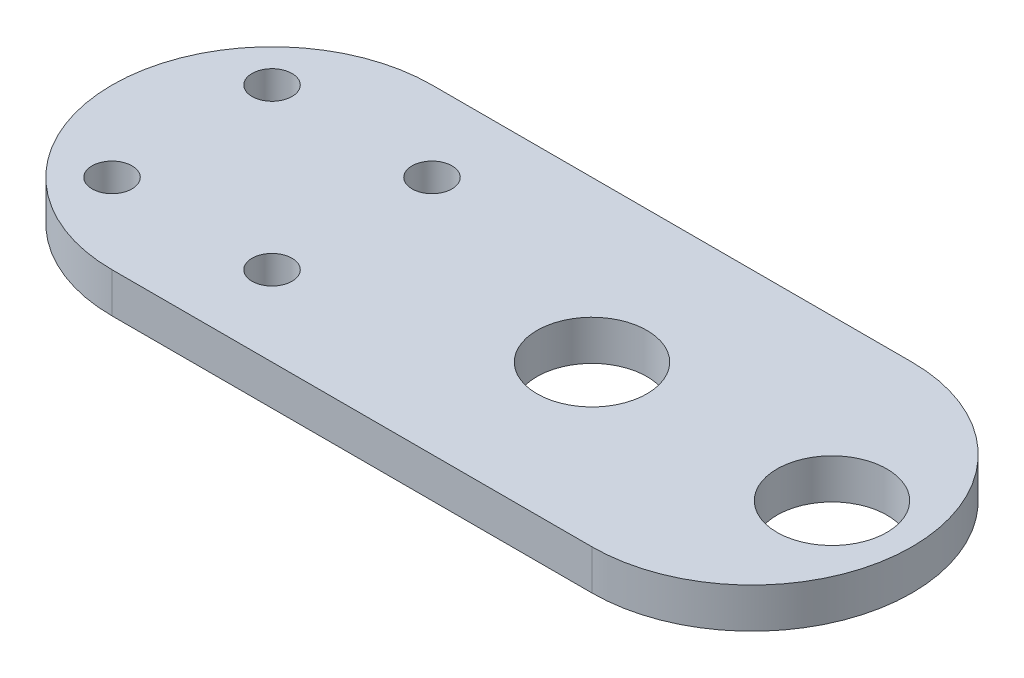
from build123d import *

# Parameters (mm, degrees)
SKETCH1_R           = 3.175
SKETCH1_R_2         = 8.72617
BOSS_EXTRUDE1_DEPTH = 6.35


with BuildPart() as part:
    # Sketch1 → Boss-Extrude1 (new body)
    with BuildSketch(Plane(origin=(0, 0, 0), x_dir=(1, 0, 0), z_dir=(0, 1, 0))):
        with BuildLine():
            Line((25.4, 0), (101.6, 0))
            ThreePointArc((101.6, 0), (127, 25.4), (101.6, 50.8))
            Line((101.6, 50.8), (25.4, 50.8))
            ThreePointArc((25.4, 50.8), (0, 25.4), (25.4, 0))
        make_face()
        with Locations((12.7, 38.1)):
            Circle(SKETCH1_R, mode=Mode.SUBTRACT)
        with Locations((38.1, 38.1)):
            Circle(SKETCH1_R, mode=Mode.SUBTRACT)
        with Locations((38.1, 12.7)):
            Circle(SKETCH1_R, mode=Mode.SUBTRACT)
        with Locations((12.7, 12.7)):
            Circle(SKETCH1_R, mode=Mode.SUBTRACT)
        with Locations((114.3, 25.4)):
            Circle(SKETCH1_R_2, mode=Mode.SUBTRACT)
        with Locations((76.2, 25.4)):
            Circle(SKETCH1_R_2, mode=Mode.SUBTRACT)
    extrude(amount=BOSS_EXTRUDE1_DEPTH)


solid = part.part
